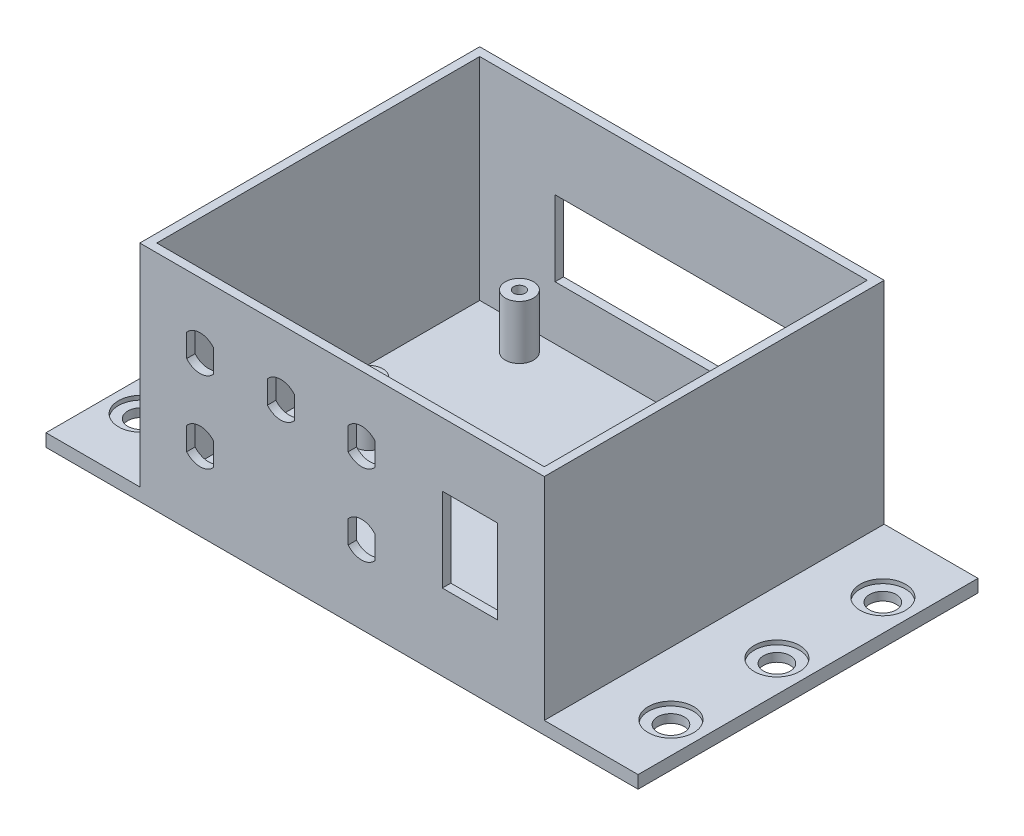
from build123d import *

# Parameters (mm, degrees)
SKETCH1_W           = 95.44
SKETCH1_H           = 80.2
SKETCH1_W_2         = 91.44
SKETCH1_H_2         = 76.2
BOSS_EXTRUDE1_DEPTH = 52.832
SKETCH2_W           = 139.7
SKETCH2_H           = 80.2
SKETCH2_R           = 3.15
BOSS_EXTRUDE2_DEPTH = 3
SKETCH3_R           = 5.35
CUT_EXTRUDE1_DEPTH  = 1
SKETCH4_R           = 3.3274
SKETCH4_R_2         = 1.3589
BOSS_EXTRUDE3_DEPTH = 12.7
CUT_EXTRUDE2_REACH  = 82.2
SKETCH5_W           = 55.88
SKETCH5_H           = 17.78
CUT_EXTRUDE3_REACH  = 82.2
SKETCH6_W           = 13
SKETCH6_H           = 19.8


with BuildPart() as part:
    # Sketch1 → Boss-Extrude1 (new body)
    with BuildSketch(Plane(origin=(0, 0, 0), x_dir=(1, 0, 0), z_dir=(0, 1, 0))):
        with Locations((2.309383501, -12.95659189)):
            Rectangle(SKETCH1_W, SKETCH1_H)
        with Locations((2.309383501, -12.95659189)):
            Rectangle(SKETCH1_W_2, SKETCH1_H_2, mode=Mode.SUBTRACT)
    extrude(amount=BOSS_EXTRUDE1_DEPTH)

    # Sketch2 → Boss-Extrude2 (add)
    with BuildSketch(Plane(origin=(0, 0, 0), x_dir=(1, 0, 0), z_dir=(0, 1, 0))):
        with Locations((2.309383501, -12.95659189)):
            Rectangle(SKETCH2_W, SKETCH2_H)
        with Locations((-60.190616499, 12.04340811)):
            Circle(SKETCH2_R, mode=Mode.SUBTRACT)
        with Locations((64.809383501, 12.04340811)):
            Circle(SKETCH2_R, mode=Mode.SUBTRACT)
        with Locations((-60.190616499, -37.95659189)):
            Circle(SKETCH2_R, mode=Mode.SUBTRACT)
        with Locations((64.809383501, -37.95659189)):
            Circle(SKETCH2_R, mode=Mode.SUBTRACT)
        with Locations((-60.190616499, -12.95659189)):
            Circle(SKETCH2_R, mode=Mode.SUBTRACT)
        with Locations((64.809383501, -12.95659189)):
            Circle(SKETCH2_R, mode=Mode.SUBTRACT)
    extrude(amount=BOSS_EXTRUDE2_DEPTH)

    # Sketch3 → Cut-Extrude1 (cut)
    with BuildSketch(Plane(origin=(0, 3, 0), x_dir=(1, 0, 0), z_dir=(0, 1, 0))):
        with Locations((-60.190616499, 12.04340811)):
            Circle(SKETCH3_R)
        with Locations((-60.190616499, -12.95659189)):
            Circle(SKETCH3_R)
        with Locations((-60.190616499, -37.95659189)):
            Circle(SKETCH3_R)
        with Locations((64.809383501, 12.04340811)):
            Circle(SKETCH3_R)
        with Locations((64.809383501, -12.95659189)):
            Circle(SKETCH3_R)
        with Locations((64.809383501, -37.95659189)):
            Circle(SKETCH3_R)
    extrude(amount=-CUT_EXTRUDE1_DEPTH, mode=Mode.SUBTRACT)

    # Sketch4 → Boss-Extrude3 (add)
    with BuildSketch(Plane(origin=(0, 3, 0), x_dir=(1, 0, 0), z_dir=(0, 1, 0))):
        with Locations((-28.170616499, 19.27600811)):
            Circle(SKETCH4_R)
        with Locations((-28.170616499, 19.27600811)):
            Circle(SKETCH4_R_2, mode=Mode.SUBTRACT)
        with Locations((32.789383501, 19.27600811)):
            Circle(SKETCH4_R)
        with Locations((32.789383501, 19.27600811)):
            Circle(SKETCH4_R_2, mode=Mode.SUBTRACT)
        with Locations((32.789383501, -16.28399189)):
            Circle(SKETCH4_R)
        with Locations((32.789383501, -16.28399189)):
            Circle(SKETCH4_R_2, mode=Mode.SUBTRACT)
        with Locations((-28.170616499, -16.28399189)):
            Circle(SKETCH4_R)
        with Locations((-28.170616499, -16.28399189)):
            Circle(SKETCH4_R_2, mode=Mode.SUBTRACT)
    extrude(amount=BOSS_EXTRUDE3_DEPTH)

    # Sketch5 → Cut-Extrude2 (cut, up to next)
    with BuildSketch(Plane(origin=(0, 0, -27.14340811), x_dir=(-1, 0, 0), z_dir=(0, 0, -1)), mode=Mode.PRIVATE) as cut_extrude2_sk1:
        with Locations((-2.309383501, 24.59)):
            Rectangle(SKETCH5_W, SKETCH5_H)
    cut_extrude2_tool1 = extrude(cut_extrude2_sk1.sketch, amount=-CUT_EXTRUDE2_REACH, mode=Mode.PRIVATE) & part.part
    add(cut_extrude2_tool1.solids().sort_by_distance((2.309384, 24.59, -27.143408))[0], mode=Mode.SUBTRACT)

    # Sketch6 → Cut-Extrude3 (cut, up to next)
    with BuildSketch(Plane.XY.offset(53.05659189), mode=Mode.PRIVATE) as cut_extrude3_sk1:
        with BuildLine():
            Line((-34.353116499, 40.137590136), (-34.353116499, 34.744409864))
            ThreePointArc((-34.353116499, 34.744409864), (-31.178116499, 33.2754), (-28.003116499, 34.744409864))
            Line((-28.003116499, 34.744409864), (-28.003116499, 40.137590136))
            ThreePointArc((-28.003116499, 40.137590136), (-31.178116499, 41.6066), (-34.353116499, 40.137590136))
        make_face()
    cut_extrude3_tool1 = extrude(cut_extrude3_sk1.sketch, amount=-CUT_EXTRUDE3_REACH, mode=Mode.PRIVATE) & part.part
    add(cut_extrude3_tool1.solids().sort_by_distance((-31.178116, 37.441, 53.056592))[0], mode=Mode.SUBTRACT)
    # Sketch6 → Cut-Extrude3 (cut, up to next)
    with BuildSketch(Plane.XY.offset(53.05659189), mode=Mode.PRIVATE) as cut_extrude3_sk2:
        with BuildLine():
            Line((-15.303116499, 40.137590136), (-15.303116499, 34.744409864))
            ThreePointArc((-15.303116499, 34.744409864), (-12.128116499, 33.2754), (-8.953116499, 34.744409864))
            Line((-8.953116499, 34.744409864), (-8.953116499, 40.137590136))
            ThreePointArc((-8.953116499, 40.137590136), (-12.128116499, 41.6066), (-15.303116499, 40.137590136))
        make_face()
    cut_extrude3_tool2 = extrude(cut_extrude3_sk2.sketch, amount=-CUT_EXTRUDE3_REACH, mode=Mode.PRIVATE) & part.part
    add(cut_extrude3_tool2.solids().sort_by_distance((-12.128116, 37.441, 53.056592))[0], mode=Mode.SUBTRACT)
    # Sketch6 → Cut-Extrude3 (cut, up to next)
    with BuildSketch(Plane.XY.offset(53.05659189), mode=Mode.PRIVATE) as cut_extrude3_sk3:
        with BuildLine():
            Line((3.746883501, 40.137590136), (3.746883501, 34.744409864))
            ThreePointArc((3.746883501, 34.744409864), (6.921883501, 33.2754), (10.096883501, 34.744409864))
            Line((10.096883501, 34.744409864), (10.096883501, 40.137590136))
            ThreePointArc((10.096883501, 40.137590136), (6.921883501, 41.6066), (3.746883501, 40.137590136))
        make_face()
    cut_extrude3_tool3 = extrude(cut_extrude3_sk3.sketch, amount=-CUT_EXTRUDE3_REACH, mode=Mode.PRIVATE) & part.part
    add(cut_extrude3_tool3.solids().sort_by_distance((6.921884, 37.441, 53.056592))[0], mode=Mode.SUBTRACT)
    # Sketch6 → Cut-Extrude3 (cut, up to next)
    with BuildSketch(Plane.XY.offset(53.05659189), mode=Mode.PRIVATE) as cut_extrude3_sk4:
        with BuildLine():
            Line((-34.353116499, 21.087590136), (-34.353116499, 15.694409864))
            ThreePointArc((-34.353116499, 15.694409864), (-31.178116499, 14.2254), (-28.003116499, 15.694409864))
            Line((-28.003116499, 15.694409864), (-28.003116499, 21.087590136))
            ThreePointArc((-28.003116499, 21.087590136), (-31.178116499, 22.5566), (-34.353116499, 21.087590136))
        make_face()
    cut_extrude3_tool4 = extrude(cut_extrude3_sk4.sketch, amount=-CUT_EXTRUDE3_REACH, mode=Mode.PRIVATE) & part.part
    add(cut_extrude3_tool4.solids().sort_by_distance((-31.178116, 18.391, 53.056592))[0], mode=Mode.SUBTRACT)
    # Sketch6 → Cut-Extrude3 (cut, up to next)
    with BuildSketch(Plane.XY.offset(53.05659189), mode=Mode.PRIVATE) as cut_extrude3_sk5:
        with BuildLine():
            Line((3.746883501, 21.087590136), (3.746883501, 15.694409864))
            ThreePointArc((3.746883501, 15.694409864), (6.921883501, 14.2254), (10.096883501, 15.694409864))
            Line((10.096883501, 15.694409864), (10.096883501, 21.087590136))
            ThreePointArc((10.096883501, 21.087590136), (6.921883501, 22.5566), (3.746883501, 21.087590136))
        make_face()
    cut_extrude3_tool5 = extrude(cut_extrude3_sk5.sketch, amount=-CUT_EXTRUDE3_REACH, mode=Mode.PRIVATE) & part.part
    add(cut_extrude3_tool5.solids().sort_by_distance((6.921884, 18.391, 53.056592))[0], mode=Mode.SUBTRACT)
    # Sketch6 → Cut-Extrude3 (cut, up to next)
    with BuildSketch(Plane.XY.offset(53.05659189), mode=Mode.PRIVATE) as cut_extrude3_sk6:
        with Locations((32.471883501, 27.916)):
            Rectangle(SKETCH6_W, SKETCH6_H)
    cut_extrude3_tool6 = extrude(cut_extrude3_sk6.sketch, amount=-CUT_EXTRUDE3_REACH, mode=Mode.PRIVATE) & part.part
    add(cut_extrude3_tool6.solids().sort_by_distance((32.471884, 27.916, 53.056592))[0], mode=Mode.SUBTRACT)


solid = part.part
